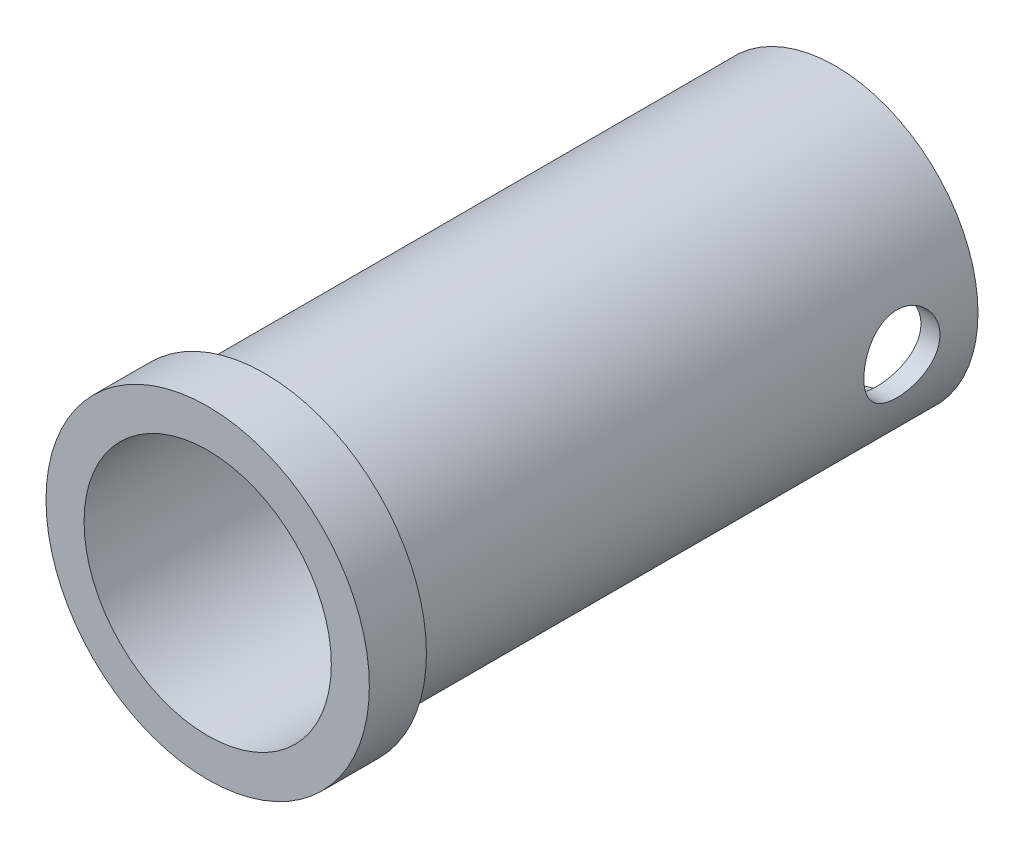
from build123d import *

# Parameters (mm, degrees)
ESBO_O1_R                  = 8.5
ESBO_O1_R_2                = 6.5
RESSALTO_EXTRUS_O1_DEPTH   = 3
ESBO_O3_R                  = 7.5
ESBO_O3_R_2                = 6.5
RESSALTO_EXTRUS_O3_DEPTH   = 30
ESBO_O4_R                  = 2
CORTE_EXTRUS_O1_DEPTH      = 9.5
CORTE_EXTRUS_O1_DEPTH_BACK = 9.5


with BuildPart() as part:
    # Esboço1 → Ressalto-extrusão1 (new body)
    with BuildSketch(Plane.XY):
        Circle(ESBO_O1_R)
        Circle(ESBO_O1_R_2, mode=Mode.SUBTRACT)
    extrude(amount=RESSALTO_EXTRUS_O1_DEPTH)

    # Esboço3 → Ressalto-extrusão3 (add)
    with BuildSketch(Plane(origin=(0, 0, 0), x_dir=(-1, 0, 0), z_dir=(0, 0, -1))):
        Circle(ESBO_O3_R)
        Circle(ESBO_O3_R_2, mode=Mode.SUBTRACT)
    extrude(amount=RESSALTO_EXTRUS_O3_DEPTH)

    # Esboço4 → Corte-extrusão1 (cut, two sides)
    with BuildSketch(Plane(origin=(0, 0, 0), x_dir=(0, 0, -1), z_dir=(1, 0, 0))) as corte_extrus_o1_sk:
        with Locations((26, 0)):
            Circle(ESBO_O4_R)
    extrude(amount=CORTE_EXTRUS_O1_DEPTH, mode=Mode.SUBTRACT)
    extrude(corte_extrus_o1_sk.sketch, amount=-CORTE_EXTRUS_O1_DEPTH_BACK, mode=Mode.SUBTRACT)


solid = part.part
